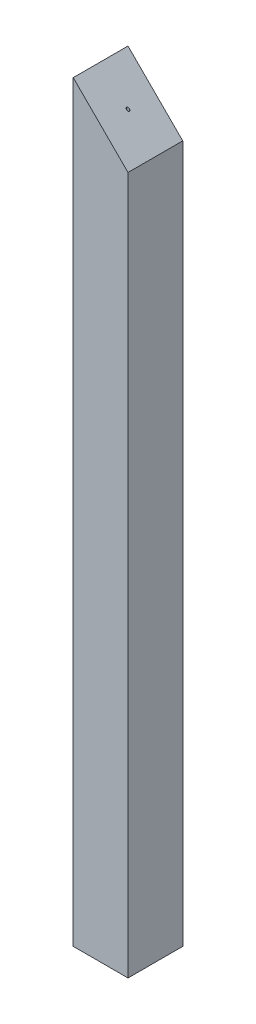
from build123d import *

# Parameters (mm, degrees)
SKETCH1_W               = 25.4
SKETCH1_H               = 25.4
BOSS_EXTRUDE1_DEPTH     = 174.485
CUT_EXTRUDE1_DEPTH      = 13.7
CUT_EXTRUDE1_DEPTH_BACK = 13.7


with BuildPart() as part:
    # Sketch1 → Boss-Extrude1 (new body, symmetric)
    with BuildSketch(Plane(origin=(0, 0, 0), x_dir=(1, 0, 0), z_dir=(0, 1, 0))):
        Rectangle(SKETCH1_W, SKETCH1_H)
    extrude(amount=BOSS_EXTRUDE1_DEPTH, both=True)

    # Sketch3 → #0-80 Tapped Hole1 (revolve, cut)
    with BuildSketch(Plane(origin=(0, -174.485, 0), x_dir=(0, 0, -1), z_dir=(1, 0, 0))):
        Polygon((0, 0), (0, 20.357890611), (0.59563, 20), (0.59563, 0.768338359), (1.5113, 0), align=None)
    f_0_80_tapped_hole1 = revolve(axis=Axis((0, -180.835, 0), (0, 1, 0)), mode=Mode.SUBTRACT)

    # Mirror1: #0-80 Tapped Hole1 across plane
    add(f_0_80_tapped_hole1.mirror(Plane.ZX), mode=Mode.SUBTRACT)

    # Sketch4 → Cut-Extrude1 (cut, two sides)
    with BuildSketch(Plane.XY) as cut_extrude1_sk:
        Polygon((12.7, 174.485), (-12.7, 174.485), (12.7, 149.085), align=None)
    extrude(amount=CUT_EXTRUDE1_DEPTH, mode=Mode.SUBTRACT)
    extrude(cut_extrude1_sk.sketch, amount=-CUT_EXTRUDE1_DEPTH_BACK, mode=Mode.SUBTRACT)


solid = part.part
